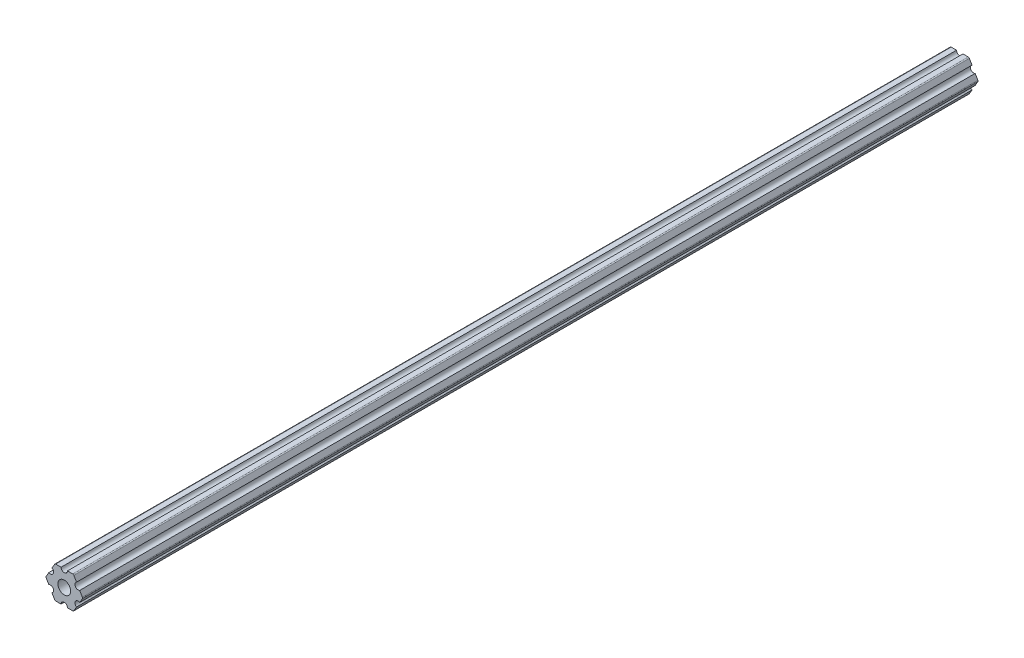
from build123d import *

# Parameters (mm, degrees)
BOSS_EXTRUDE1_DEPTH     = 355.6
SKETCH2_R               = 1.27
SKETCH2_R_2             = 2.54
CUT_EXTRUDE1_DEPTH      = 356.6
FILLET1_R               = 0.508
F_1_4_20_TAPPED_HOLE3_D = 5.1054


with BuildPart() as part:
    # Sketch1 → Boss-Extrude1 (new body)
    with BuildSketch(Plane.XY):
        Polygon((7.332348419, 0), (3.666174209, 6.35), (-3.666174209, 6.35), (-7.332348419, 0), (-3.666174209, -6.35), (3.666174209, -6.35), align=None)
    extrude(amount=BOSS_EXTRUDE1_DEPTH)

    # Sketch2 → Cut-Extrude1 (cut, through all)
    with BuildSketch(Plane.XY.offset(355.6)):
        with Locations((0, 6.35)):
            Circle(SKETCH2_R)
        with Locations((5.499261314, 3.175)):
            Circle(SKETCH2_R)
        with Locations((5.499261314, -3.175)):
            Circle(SKETCH2_R)
        with Locations((0, -6.35)):
            Circle(SKETCH2_R)
        with Locations((-5.499261314, -3.175)):
            Circle(SKETCH2_R)
        with Locations((-5.499261314, 3.175)):
            Circle(SKETCH2_R)
        Circle(SKETCH2_R_2)
    extrude(amount=-CUT_EXTRUDE1_DEPTH, mode=Mode.SUBTRACT)

    # Fillet1
    fillet1_edges = [part.edges().sort_by_distance(p)[0] for p in [
        (3.666174209, -6.35, 177.8),
        (-3.666174209, -6.35, 177.8),
        (-7.332348419, 0, 177.8),
        (-3.666174209, 6.35, 177.8),
        (3.666174209, 6.35, 177.8),
        (7.332348419, 0, 177.8),
    ]]
    fillet(fillet1_edges, radius=FILLET1_R)

    # 1/4-20 Tapped Hole3 (through all)
    with Locations(Plane.XY.offset(355.6)):
        with Locations((0, 0)):
            f_1_4_20_tapped_hole3 = Hole(F_1_4_20_TAPPED_HOLE3_D / 2)

    # Mirror1: 1/4-20 Tapped Hole3 across plane
    add(f_1_4_20_tapped_hole3.mirror(Plane.XY.offset(177.8)), mode=Mode.SUBTRACT)


solid = part.part
